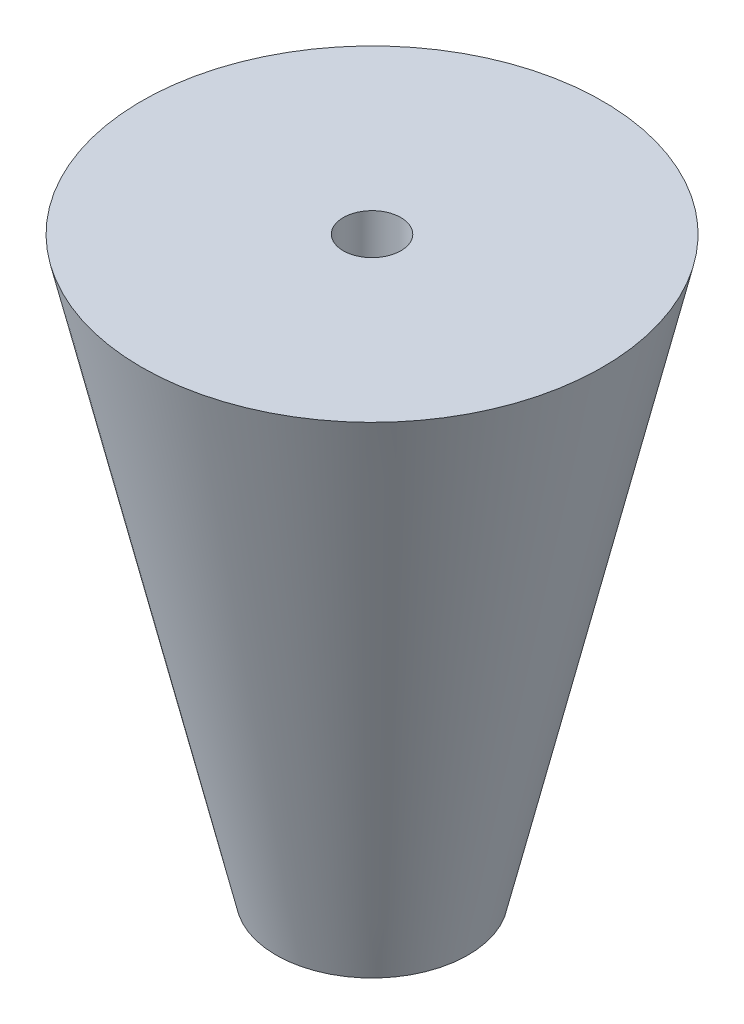
from build123d import *

# Parameters (mm, degrees)
SKETCH2_R          = 1.5
CUT_EXTRUDE1_DEPTH = 10


with BuildPart() as part:
    # Sketch1 → Revolve1 (revolve)
    with BuildSketch(Plane.XY):
        Polygon((5, 0), (12, 30), (0, 30), (0, 0), align=None)
    revolve(axis=Axis((0, 30, 0), (0, -1, 0)))

    # Sketch2 → Cut-Extrude1 (cut)
    with BuildSketch(Plane(origin=(0, 30, 0), x_dir=(1, 0, 0), z_dir=(0, 1, 0))):
        Circle(SKETCH2_R)
    extrude(amount=-CUT_EXTRUDE1_DEPTH, mode=Mode.SUBTRACT)


solid = part.part
